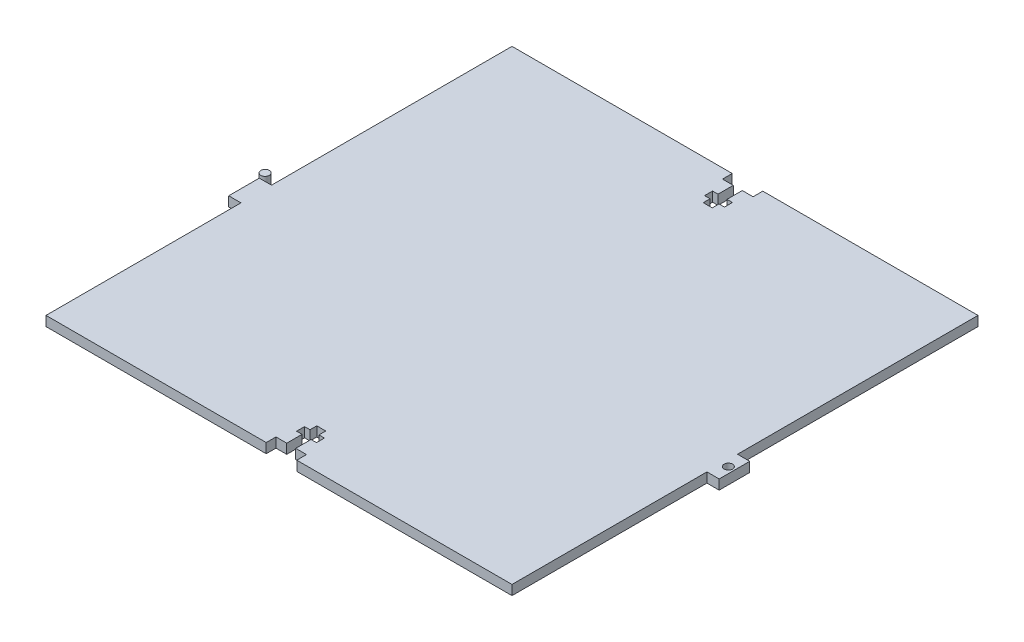
from build123d import *

# Parameters (mm, degrees)
SKETCH1_R             = 1.4
BOSS_EXTRUDE1_DEPTH   = 3.18
BOSS_EXTRUDE1_2_DEPTH = 3.18
CUT_EXTRUDE1_DEPTH    = 3.18


with BuildPart() as part:
    # Sketch1 → Boss-Extrude1 (new body)
    with BuildSketch(Plane(origin=(0, 0, 0), x_dir=(1, 0, 0), z_dir=(0, 1, 0))):
        with Locations((-81.54562107, 0)):
            Circle(SKETCH1_R)
    extrude(amount=BOSS_EXTRUDE1_DEPTH)


with BuildPart() as body_2:
    # Sketch1 → Boss-Extrude1 2 (new body)
    with BuildSketch(Plane(origin=(0, 0, 0), x_dir=(1, 0, 0), z_dir=(0, 1, 0))):
        Polygon((-77.02, 76.2), (-5.292081761, 76.2), (3.652081761, 76.2), (75.38, 76.2), (75.38, -2.448884984), (79.38, -2.448884984), (79.38, -12.448884984), (75.38, -12.448884984), (75.38, -76.2), (3.652081761, -76.2), (-5.292081761, -76.2), (-77.02, -76.2), (-77.02, -12.448884984), (-81.02, -12.448884984), (-81.02, -2.448884984), (-77.02, -2.448884984), align=None)
        with Locations((77.38, -7.448884984)):
            Circle(SKETCH1_R, mode=Mode.SUBTRACT)
    extrude(amount=BOSS_EXTRUDE1_2_DEPTH)

    # Sketch2 → Cut-Extrude1 (cut)
    with BuildSketch(Plane(origin=(0, 3.18, 0), x_dir=(1, 0, 0), z_dir=(0, 1, 0))):
        Polygon((5, 76.2), (-5, 76.2), (-5, 73.02), (-1.47, 73.02), (-1.47, 68.02), (-3.25, 68.02), (-3.25, 65.42), (-1.47, 65.42), (-1.47, 63.2), (1.47, 63.2), (1.47, 65.42), (3.25, 65.42), (3.25, 68.02), (1.47, 68.02), (1.47, 73.02), (5, 73.02), align=None)
    cut_extrude1 = extrude(amount=-CUT_EXTRUDE1_DEPTH, mode=Mode.SUBTRACT)

    # Mirror4: Cut-Extrude1 across plane
    add(cut_extrude1.mirror(Plane.XY), mode=Mode.SUBTRACT)


solid = Compound([part.part, body_2.part])
